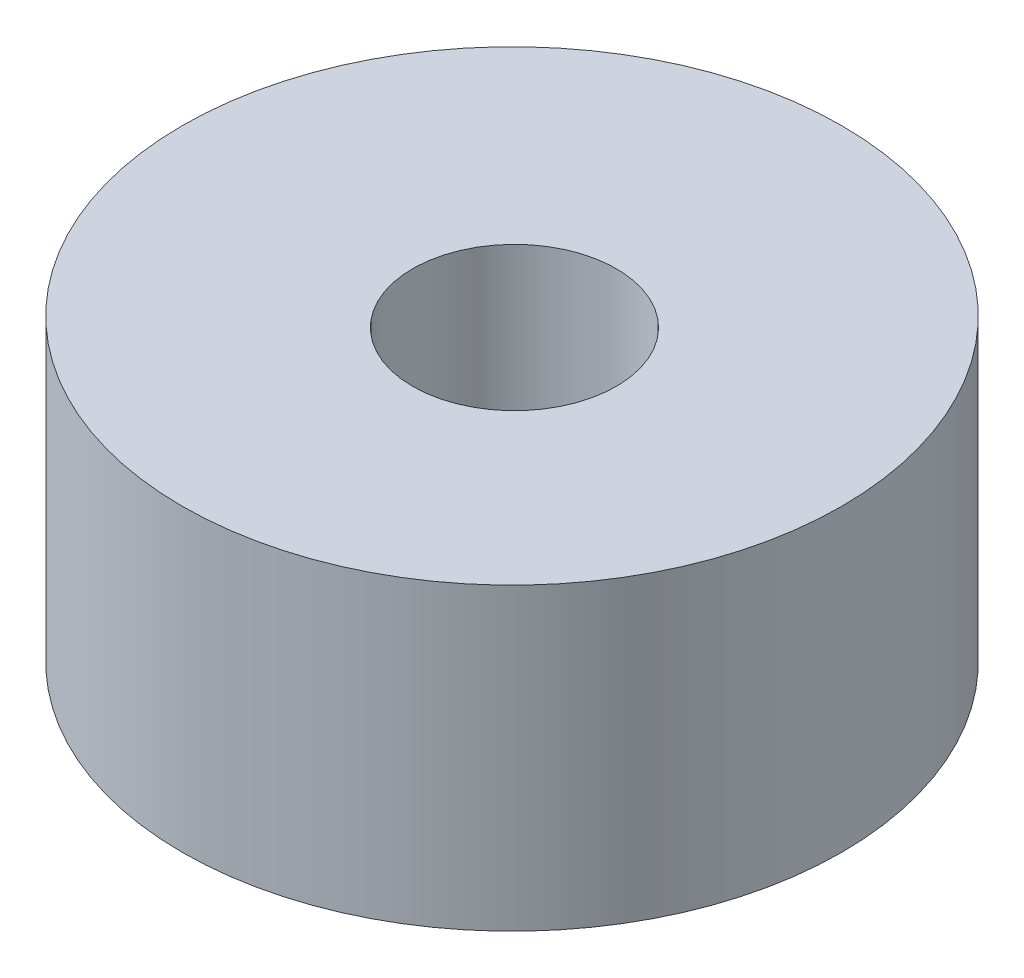
from build123d import *

# Parameters (mm, degrees)
SKETCH1_R           = 11
BOSS_EXTRUDE1_DEPTH = 10
M8_TAPPED_HOLE1_D   = 6.8


with BuildPart() as part:
    # Sketch1 → Boss-Extrude1 (new body)
    with BuildSketch(Plane(origin=(0, 0, 0), x_dir=(1, 0, 0), z_dir=(0, 1, 0))):
        Circle(SKETCH1_R)
    extrude(amount=BOSS_EXTRUDE1_DEPTH)

    # M8 Tapped Hole1 (through all)
    with Locations(Plane(origin=(0.37570957, 10, 0.293209501), x_dir=(0, 0, 1), z_dir=(0, 1, 0))):
        with Locations((0, 0)):
            Hole(M8_TAPPED_HOLE1_D / 2)


solid = part.part
